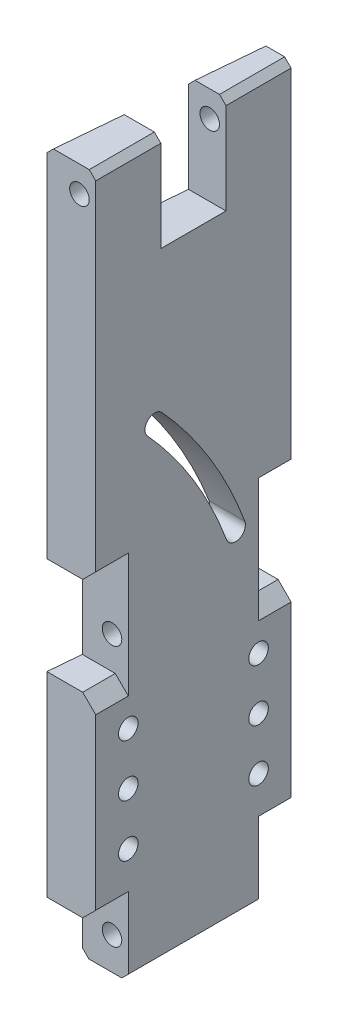
from build123d import *

# Parameters (mm, degrees)
BOSS_EXTRUDE1_DEPTH = 19.05
SKETCH2_R           = 3.81
CUT_EXTRUDE1_DEPTH  = 64.5
SKETCH3_R           = 3.81
CUT_EXTRUDE2_DEPTH  = 64.5
CUT_EXTRUDE3_DEPTH  = 20.05
SKETCH6_R           = 3.81
CUT_EXTRUDE4_DEPTH  = 20.05
LPATTERN1_COUNT     = 3
LPATTERN1_PITCH     = 20.32
SKETCH7_W           = 25.4
SKETCH7_H           = 38.1
CUT_EXTRUDE5_DEPTH  = 20.05
CUT_EXTRUDE6_DEPTH  = 280.4
SKETCH9_R           = 3.81
CUT_EXTRUDE7_DEPTH  = 76.2
CHAMFER1_SIZE       = 2.54
CHAMFER2_SIZE       = 5.08


with BuildPart() as part:
    # Sketch1 → Boss-Extrude1 (new body)
    with BuildSketch(Plane(origin=(0, 0, 0), x_dir=(0, 0, -1), z_dir=(1, 0, 0))):
        Polygon((0, 0), (0, 25.4), (-12.7, 25.4), (-12.7, 101.6), (0, 101.6), (0, 139.7), (-12.7, 139.7), (-12.7, 279.4), (63.5, 279.4), (63.5, 139.7), (50.8, 139.7), (50.8, 101.6), (63.5, 101.6), (63.5, 25.4), (50.8, 25.4), (50.8, 0), align=None)
    extrude(amount=BOSS_EXTRUDE1_DEPTH)

    # Sketch2 → Cut-Extrude1 (cut, through all)
    with BuildSketch(Plane.XY):
        with Locations((12.7, 114.3)):
            Circle(SKETCH2_R)
    extrude(amount=-CUT_EXTRUDE1_DEPTH, mode=Mode.SUBTRACT)

    # Sketch3 → Cut-Extrude2 (cut, through all)
    with BuildSketch(Plane.XY):
        with Locations((12.7, 12.7)):
            Circle(SKETCH3_R)
    extrude(amount=-CUT_EXTRUDE2_DEPTH, mode=Mode.SUBTRACT)

    # Sketch4 → Cut-Extrude3 (cut, through all)
    with BuildSketch(Plane(origin=(19.05, 0, 0), x_dir=(0, 0, -1), z_dir=(1, 0, 0))):
        with BuildLine():
            ThreePointArc((45.433317408, 132.844708156), (31.8216378, 160.842664311), (13.115249698, 185.727085439))
            ThreePointArc((13.115249698, 185.727085439), (7.732489274, 185.968104562), (7.491470151, 180.585344138))
            ThreePointArc((7.491470151, 180.585344138), (25.319688182, 156.869120406), (38.292368451, 130.185526327))
            ThreePointArc((38.292368451, 130.185526327), (43.192433844, 127.944642763), (45.433317408, 132.844708156))
        make_face()
    extrude(amount=-CUT_EXTRUDE3_DEPTH, mode=Mode.SUBTRACT)

    # Sketch6 → Cut-Extrude4 (cut, through all)
    with BuildSketch(Plane(origin=(19.05, 0, 0), x_dir=(0, 0, -1), z_dir=(1, 0, 0))):
        with Locations((0, 44.904409269)):
            Circle(SKETCH6_R)
        with Locations((50.8, 44.904409269)):
            Circle(SKETCH6_R)
    cut_extrude4 = extrude(amount=-CUT_EXTRUDE4_DEPTH, mode=Mode.SUBTRACT)

    # LPattern1: Cut-Extrude4 ×3
    with Locations(*[(0, i * LPATTERN1_PITCH, 0) for i in range(1, LPATTERN1_COUNT)]):
        add(cut_extrude4, mode=Mode.SUBTRACT)

    # Sketch7 → Cut-Extrude5 (cut, through all)
    with BuildSketch(Plane(origin=(19.05, 0, 0), x_dir=(0, 0, -1), z_dir=(1, 0, 0))):
        with Locations((25.4, 260.35)):
            Rectangle(SKETCH7_W, SKETCH7_H)
    extrude(amount=-CUT_EXTRUDE5_DEPTH, mode=Mode.SUBTRACT)

    # Sketch8 → Cut-Extrude6 (cut, through all)
    with BuildSketch(Plane(origin=(0, 0, 0), x_dir=(1, 0, 0), z_dir=(0, 1, 0))):
        Polygon((0, 63.5), (6.666636161, 63.5), (0, -12.7), align=None)
    extrude(amount=CUT_EXTRUDE6_DEPTH, mode=Mode.SUBTRACT)

    # Sketch9 → Cut-Extrude7 (cut, symmetric)
    with BuildSketch(Plane.XY):
        with Locations((12.7, 269.24)):
            Circle(SKETCH9_R)
    extrude(amount=CUT_EXTRUDE7_DEPTH, both=True, mode=Mode.SUBTRACT)

    # Chamfer1
    chamfer1_edges = [part.edges().sort_by_distance(p)[0] for p in [
        (1.111106027, 279.4, 0),
        (5.555530134, 279.4, -50.8),
        (3.33331808, 0, -25.4),
        (19.05, 279.4, -50.8),
        (19.05, 0, -25.4),
        (19.05, 279.4, 0),
    ]]
    chamfer(chamfer1_edges, length=CHAMFER1_SIZE)

    # Chamfer2
    chamfer2_edges = [part.edges().sort_by_distance(p)[0] for p in [
        (19.05, 25.4, -57.15),
        (19.05, 101.6, -57.15),
        (19.05, 139.7, -57.15),
        (19.05, 139.7, 6.35),
        (19.05, 101.6, 6.35),
        (19.05, 25.4, 6.35),
    ]]
    chamfer(chamfer2_edges, length=CHAMFER2_SIZE)


solid = part.part
